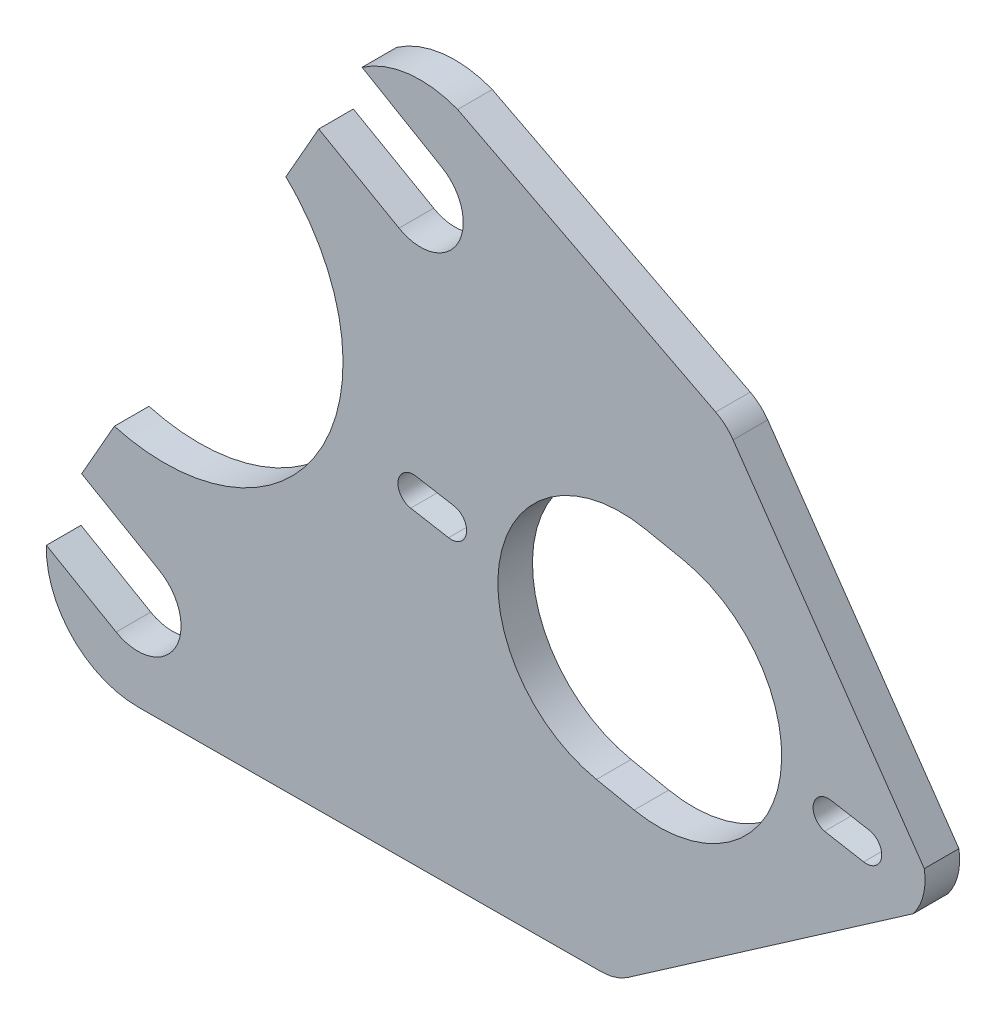
from build123d import *

# Parameters (mm, degrees)
BOSS_EXTRUDE1_DEPTH = 3.6
CUT_EXTRUDE1_DEPTH  = 10
BOSS_EXTRUDE2_DEPTH = 3.6
FILLET2_R           = 5
FILLET3_R           = 5
CUT_EXTRUDE4_DEPTH  = 10


with BuildPart() as part:
    # Model → Boss-Extrude1 (new body)
    with BuildSketch(Plane.XY):
        with BuildLine():
            ThreePointArc((50.228535872, 45.395569416), (52.924019536, 38.465315249), (59.782889449, 35.593041144))
            Line((59.782889449, 35.593041144), (113.827054853, 35.866410266))
            Line((113.827054853, 35.866410266), (139.096203594, 35.866410266))
            Line((139.096203594, 35.866410266), (143.174409672, 59.637869067))
            Line((143.174409672, 59.637869067), (92.999499813, 106.036140475))
            ThreePointArc((92.999499813, 106.036140475), (87.882885081, 106.693381362), (83.060832366, 104.860482154))
            Line((83.060832366, 104.860482154), (91.356130692, 100.009349623))
            ThreePointArc((91.356130692, 100.009349623), (92.985626216, 93.927680535), (86.903957127, 92.29818501))
            Line((86.903957127, 92.29818501), (78.555180285, 97.056247849))
            Line((78.555180285, 97.056247849), (75.134981042, 91.038441072))
            add(Edge.make_bspline(
                [(57.29513209, 59.649403086), (71.571605605, 55.696337304), (78.704068896, 68.245836001), (85.836532187, 80.795334698), (75.134981042, 91.038441072)],
                knots=[4.965698504, 4.965698504, 4.965698504, 6.283185307, 6.283185307, 7.60067211, 7.60067211, 7.60067211], degree=2, weights=[1, 0.790762049, 1, 0.790762049, 1]))
            Line((57.29513209, 59.649403086), (53.897000793, 53.67042464))
            Line((53.897000793, 53.67042464), (61.984810396, 49.000227317))
            ThreePointArc((61.984810396, 49.000227318), (63.628806933, 42.852421177), (57.481000793, 41.20842464))
            Line((57.481000793, 41.20842464), (50.228535872, 45.395569416))
        make_face()
        with BuildLine():
            ThreePointArc((131.161569827, 60.100370477), (130.006797557, 61.990672634), (131.847360572, 63.22317782))
            Line((131.847360572, 63.22317782), (135.786606546, 62.52866997))
            ThreePointArc((135.786606546, 62.52866997), (137.0843143, 60.674111066), (135.228884267, 59.377649136))
            Line((135.228884267, 59.377649136), (131.161569827, 60.100370477))
        make_face(mode=Mode.SUBTRACT)
        with BuildLine():
            Line((88.671682294, 70.836214946), (92.610913304, 70.141622223))
            ThreePointArc((92.610913304, 70.141622223), (93.908768619, 68.28809273), (92.055239126, 66.990237415))
            Line((92.055239126, 66.990237415), (88.116008116, 67.684830138))
            ThreePointArc((88.116008116, 67.684830138), (86.818152801, 69.538359631), (88.671682294, 70.836214946))
        make_face(mode=Mode.SUBTRACT)
        with BuildLine():
            Line((112.523140626, 77.999162994), (116.44350371, 77.204963218))
            ThreePointArc((116.44350371, 77.204963218), (126.447226298, 62.118362064), (111.360625143, 52.114639476))
            Line((111.360625143, 52.114639476), (107.440262059, 52.908839252))
            ThreePointArc((107.440262059, 52.908839252), (97.436539471, 67.995440406), (112.523140626, 77.999162994))
        make_face(mode=Mode.SUBTRACT)
    extrude(amount=BOSS_EXTRUDE1_DEPTH)

    # Sketch1 → Cut-Extrude1 (cut)
    with BuildSketch(Plane(origin=(0, 0, 0), x_dir=(-1, 0, 0), z_dir=(0, 0, -1))):
        Polygon((-111.037829948, 36.937189918), (-140.869018833, 57.620278897), (-151.014903895, 64.654803881), (-139.168658951, 25.748061744), (-100.690846138, 27.008956511), (-96.89763307, 27.13325782), align=None)
    extrude(amount=-CUT_EXTRUDE1_DEPTH, mode=Mode.SUBTRACT)

    # Sketch2 → Boss-Extrude2 (add)
    with BuildSketch(Plane.XY.offset(3.6)):
        Polygon((92.999499813, 106.036140475), (143.024707588, 59.776303156), (141.625060148, 61.795012605), (120.941971169, 91.62620149), align=None)
    extrude(amount=-BOSS_EXTRUDE2_DEPTH)

    # Fillet2
    fillet2_edges = [part.edges().sort_by_distance(p)[0] for p in [
        (109.461597782, 35.844328675, 1.8),
    ]]
    fillet(fillet2_edges, radius=FILLET2_R)

    # Fillet3
    fillet3_edges = [part.edges().sort_by_distance(p)[0] for p in [
        (120.941971169, 91.62620149, 1.8),
    ]]
    fillet(fillet3_edges, radius=FILLET3_R)

    # Sketch4 → Cut-Extrude4 (cut)
    with BuildSketch(Plane(origin=(0, 0, 0), x_dir=(-1, 0, 0), z_dir=(0, 0, -1))):
        with BuildLine():
            Line((-139.736629218, 65.356597838), (-145.722109327, 59.610067808))
            Line((-145.722109327, 59.610067808), (-139.736629218, 56.549346698))
            ThreePointArc((-139.736629218, 56.549346698), (-141.61342704, 60.952972268), (-139.736629218, 65.356597838))
        make_face()
    extrude(amount=-CUT_EXTRUDE4_DEPTH, mode=Mode.SUBTRACT)


solid = part.part
